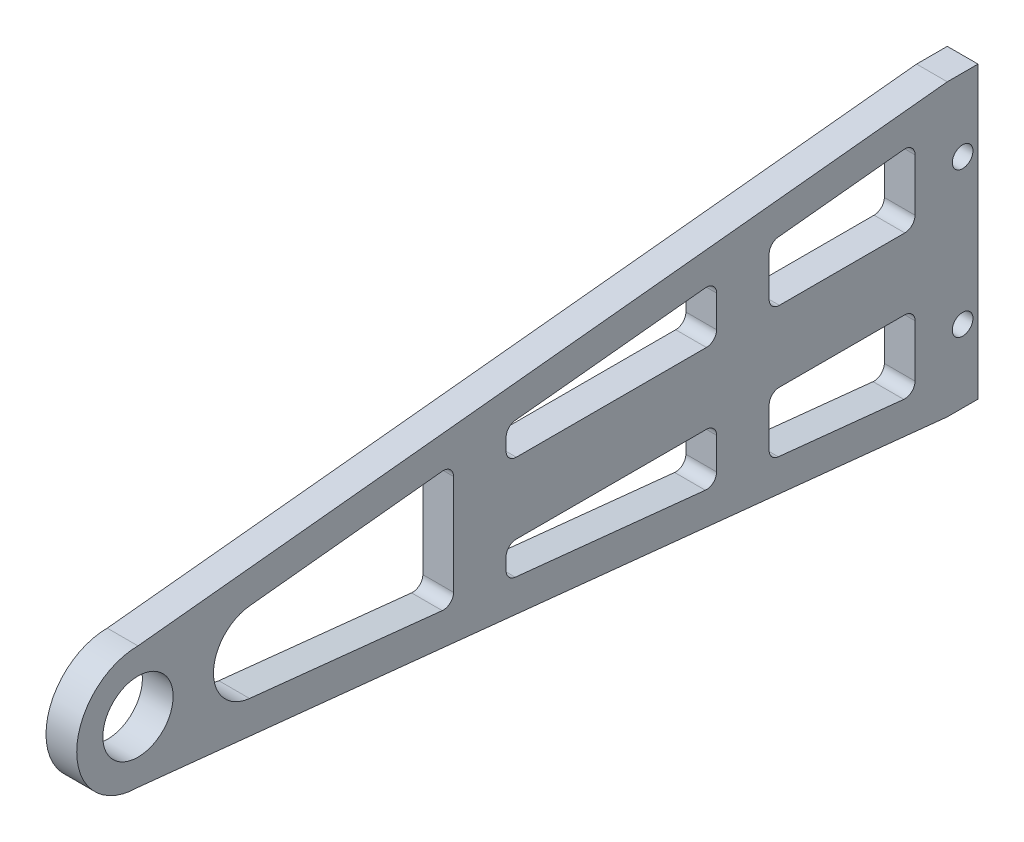
from build123d import *

# Parameters (mm, degrees)
SKETCH1_R            = 5.44942
BOSS_EXTRUDE1_DEPTH  = 2.3815
M3_CLEARANCE_HOLE1_D = 3.2


with BuildPart() as part:
    # Sketch1 → Boss-Extrude1 (new body, symmetric)
    with BuildSketch(Plane(origin=(0, 0, 0), x_dir=(0, 0, -1), z_dir=(1, 0, 0))):
        with BuildLine():
            Line((0, 9.5), (125.5, 22.5))
            Line((125.5, 22.5), (130.263, 22.5))
            Line((130.263, 22.5), (130.263, -22.5))
            Line((130.263, -22.5), (125.5, -22.5))
            Line((125.5, -22.5), (0, -9.5))
            ThreePointArc((0, -9.5), (-9.5, 0), (0, 9.5))
        make_face()
        Circle(SKETCH1_R, mode=Mode.SUBTRACT)
        with BuildLine():
            Line((17.302023212, 6.21531268), (47.183955708, 9.358046468))
            ThreePointArc((47.183955708, 9.358046468), (48.412205474, 8.959031889), (48.9375, 7.779254036))
            Line((48.9375, 7.779254036), (48.9375, -7.779257299))
            ThreePointArc((48.9375, -7.779257299), (48.412206559, -8.959034175), (47.183958614, -9.358050037))
            Line((47.183958614, -9.358050037), (17.302047548, -6.215374112))
            ThreePointArc((17.302047548, -6.215374112), (11.709307369, -4.1665e-05), (17.302023212, 6.21531268))
        make_face(mode=Mode.SUBTRACT)
        with BuildLine():
            Line((120.5, 15.194881882), (120.5, 7.0875))
            ThreePointArc((120.5, 7.0875), (120.035032015, 5.964967985), (118.9125, 5.5))
            Line((118.9125, 5.5), (99.4625, 5.5))
            ThreePointArc((99.4625, 5.5), (98.339967985, 5.964967985), (97.875, 7.0875))
            Line((97.875, 7.0875), (97.875, 13.180140846))
            ThreePointArc((97.875, 13.180140846), (98.283555786, 14.243271501), (99.298932964, 14.759191851))
            Line((99.298932964, 14.759191851), (118.748932964, 16.773932886))
            ThreePointArc((118.748932964, 16.773932886), (119.975630655, 16.373826096), (120.5, 15.194881882))
        make_face(mode=Mode.SUBTRACT)
        with BuildLine():
            Line((120.5, -15.194881882), (120.5, -7.0875))
            ThreePointArc((120.5, -7.0875), (120.035032015, -5.964967985), (118.9125, -5.5))
            Line((118.9125, -5.5), (99.4625, -5.5))
            ThreePointArc((99.4625, -5.5), (98.339967985, -5.964967985), (97.875, -7.0875))
            Line((97.875, -7.0875), (97.875, -13.180140846))
            ThreePointArc((97.875, -13.180140846), (98.283555786, -14.243271501), (99.298932964, -14.759191851))
            Line((99.298932964, -14.759191851), (118.748932964, -16.773932886))
            ThreePointArc((118.748932964, -16.773932886), (119.975630655, -16.373826096), (120.5, -15.194881882))
        make_face(mode=Mode.SUBTRACT)
        with BuildLine():
            Line((89.73075, 7.0875), (89.73075, 12.007628894))
            ThreePointArc((89.73075, 12.007628894), (89.206380655, 13.186573108), (87.979682964, 13.586679898))
            Line((87.979682964, 13.586679898), (58.505682964, 10.533596233))
            ThreePointArc((58.505682964, 10.533596233), (57.490305786, 10.017675884), (57.08175, 8.954545229))
            Line((57.08175, 8.954545229), (57.08175, 7.0875))
            ThreePointArc((57.08175, 7.0875), (57.546717985, 5.964967985), (58.66925, 5.5))
            Line((58.66925, 5.5), (88.14325, 5.5))
            ThreePointArc((88.14325, 5.5), (89.265782015, 5.964967985), (89.73075, 7.0875))
        make_face(mode=Mode.SUBTRACT)
        with BuildLine():
            Line((89.73075, -7.0875), (89.73075, -12.007628894))
            ThreePointArc((89.73075, -12.007628894), (89.206380655, -13.186573108), (87.979682964, -13.586679898))
            Line((87.979682964, -13.586679898), (58.505682964, -10.533596233))
            ThreePointArc((58.505682964, -10.533596233), (57.490305786, -10.017675884), (57.08175, -8.954545229))
            Line((57.08175, -8.954545229), (57.08175, -7.0875))
            ThreePointArc((57.08175, -7.0875), (57.546717985, -5.964967985), (58.66925, -5.5))
            Line((58.66925, -5.5), (88.14325, -5.5))
            ThreePointArc((88.14325, -5.5), (89.265782015, -5.964967985), (89.73075, -7.0875))
        make_face(mode=Mode.SUBTRACT)
    extrude(amount=BOSS_EXTRUDE1_DEPTH, both=True)

    # M3 Clearance Hole1 (through all)
    with Locations(Plane(origin=(2.3815, 0, 0), x_dir=(0, 0, -1), z_dir=(1, 0, 0))):
        with Locations((127.8815, 11.25), (127.8815, -11.25)):
            Hole(M3_CLEARANCE_HOLE1_D / 2)


solid = part.part
